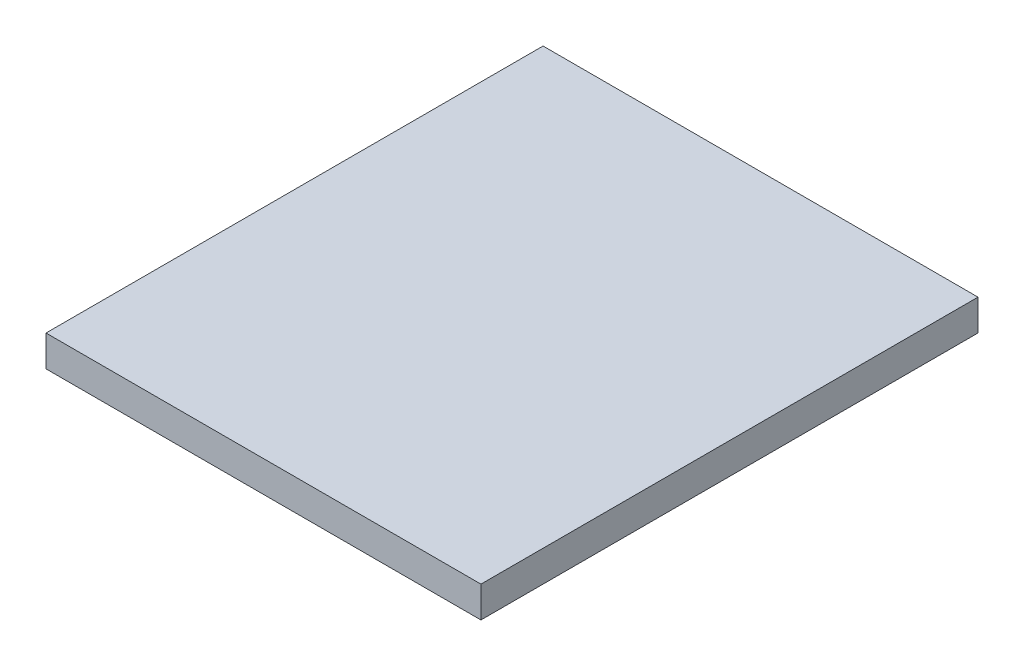
from build123d import *

# Parameters (mm, degrees)
SKETCH1_W           = 711.2
SKETCH1_H           = 812.8
BOSS_EXTRUDE1_DEPTH = 25.4


with BuildPart() as part:
    # Sketch1 → Boss-Extrude1 (new body, symmetric)
    with BuildSketch(Plane(origin=(0, 0, 0), x_dir=(1, 0, 0), z_dir=(0, 1, 0))):
        Rectangle(SKETCH1_W, SKETCH1_H)
    extrude(amount=BOSS_EXTRUDE1_DEPTH, both=True)


solid = part.part
